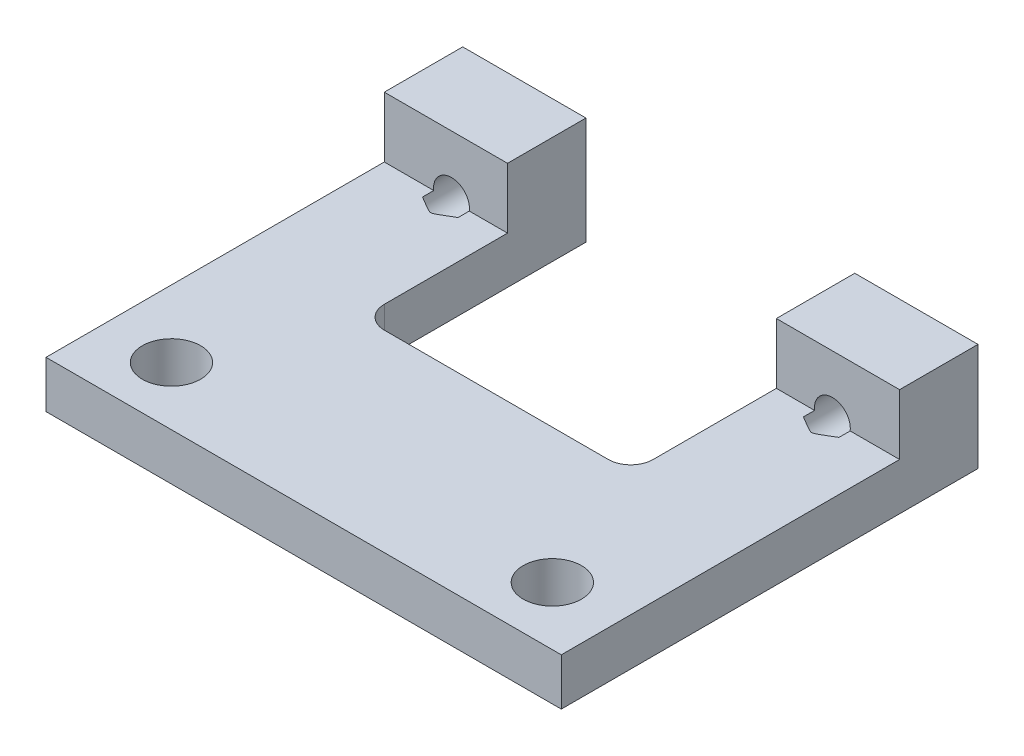
from build123d import *

# Parameters (mm, degrees)
SKETCH1_W                 = 23
SKETCH1_H                 = 18.6
BOSS_EXTRUDE1_DEPTH       = 4.8
SKETCH2_W                 = 15.1
SKETCH2_H                 = 2.7
CUT_EXTRUDE1_DEPTH        = 27.8
SKETCH3_W                 = 12
SKETCH3_H                 = 10
CUT_EXTRUDE2_DEPTH        = 27.8
M2X0_4_TAPPED_HOLE1_D     = 1.6
M2X0_4_TAPPED_HOLE1_DEPTH = 4
M2X0_4_TAPPED_HOLE1_TIP   = 0.480688495
SKETCH7_R                 = 1.3
CUT_EXTRUDE3_DEPTH        = 27.8
FILLET1_R                 = 1


with BuildPart() as part:
    # Sketch1 → Boss-Extrude1 (new body)
    with BuildSketch(Plane(origin=(0, 0, 0), x_dir=(1, 0, 0), z_dir=(0, 1, 0))):
        Rectangle(SKETCH1_W, SKETCH1_H)
    extrude(amount=BOSS_EXTRUDE1_DEPTH)

    # Sketch2 → Cut-Extrude1 (cut)
    with BuildSketch(Plane(origin=(11.5, 0, 0), x_dir=(0, 0, -1), z_dir=(1, 0, 0))):
        with Locations((-1.75, 3.45)):
            Rectangle(SKETCH2_W, SKETCH2_H)
    extrude(amount=-CUT_EXTRUDE1_DEPTH, mode=Mode.SUBTRACT)

    # Sketch3 → Cut-Extrude2 (cut)
    with BuildSketch(Plane.XZ):
        with Locations((0, -4.3)):
            Rectangle(SKETCH3_W, SKETCH3_H)
    extrude(amount=-CUT_EXTRUDE2_DEPTH, mode=Mode.SUBTRACT)

    # M2x0.4 Tapped Hole1
    with Locations(Plane(origin=(0, 0, -9.3), x_dir=(-1, 0, 0), z_dir=(0, 0, -1))):
        with Locations((-8.5, 2.2), (8.5, 2.2)):
            Hole(M2X0_4_TAPPED_HOLE1_D / 2, depth=M2X0_4_TAPPED_HOLE1_DEPTH)
            with Locations((0, 0, -(M2X0_4_TAPPED_HOLE1_DEPTH + M2X0_4_TAPPED_HOLE1_TIP / 2))):  # 118° drill point
                Cone(0, M2X0_4_TAPPED_HOLE1_D / 2, M2X0_4_TAPPED_HOLE1_TIP, mode=Mode.SUBTRACT)

    # Sketch7 → Cut-Extrude3 (cut)
    with BuildSketch(Plane.XZ):
        with Locations((-8.5, 6.7)):
            Circle(SKETCH7_R)
        with Locations((8.5, 6.7)):
            Circle(SKETCH7_R)
    extrude(amount=-CUT_EXTRUDE3_DEPTH, mode=Mode.SUBTRACT)

    # Fillet1
    fillet1_edges = [part.edges().sort_by_distance(p)[0] for p in [
        (-6, 1.05, 0.7),
        (6, 1.05, 0.7),
    ]]
    fillet(fillet1_edges, radius=FILLET1_R)


solid = part.part
